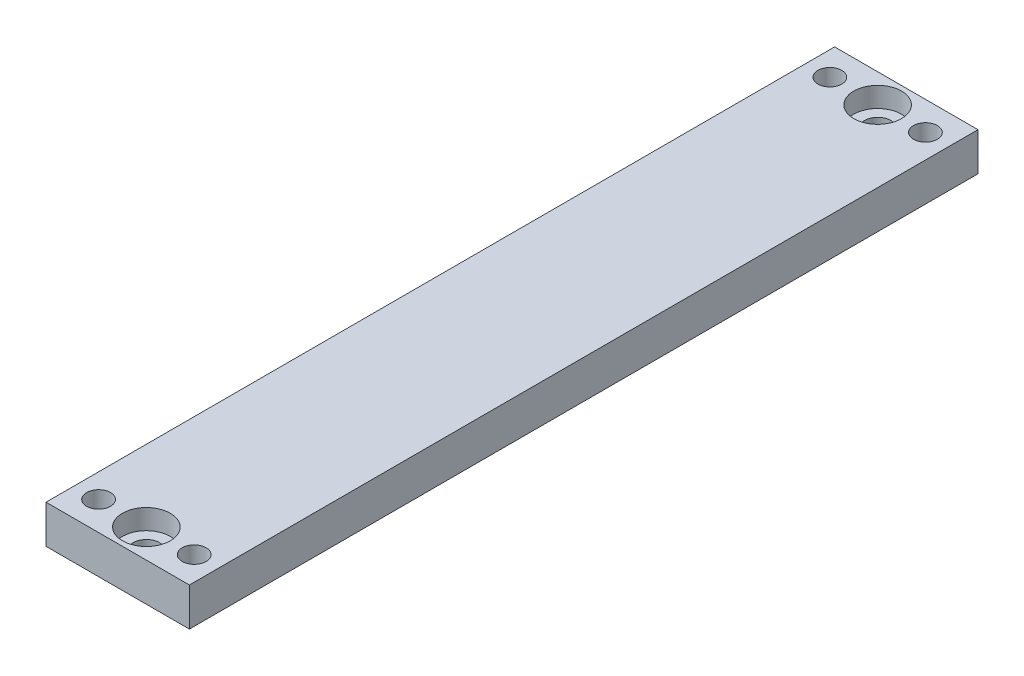
from build123d import *

# Parameters (mm, degrees)
SKETCH2_W           = 30
SKETCH2_H           = 165
BOSS_EXTRUDE1_DEPTH = 8
SKETCH3_R           = 2.75
CUT_EXTRUDE1_DEPTH  = 8
SKETCH4_R           = 5
CUT_EXTRUDE2_DEPTH  = 4.2
SKETCH5_R           = 2.5
CUT_EXTRUDE3_DEPTH  = 41.2


with BuildPart() as part:
    # Sketch2 → Boss-Extrude1 (new body)
    with BuildSketch(Plane(origin=(0, 0, 0), x_dir=(1, 0, 0), z_dir=(0, 1, 0))):
        Rectangle(SKETCH2_W, SKETCH2_H)
    extrude(amount=BOSS_EXTRUDE1_DEPTH)

    # Sketch3 → Cut-Extrude1 (cut)
    with BuildSketch(Plane(origin=(0, 8, 0), x_dir=(1, 0, 0), z_dir=(0, 1, 0))):
        with Locations((0, -76.5)):
            Circle(SKETCH3_R)
        with Locations((0, 76.5)):
            Circle(SKETCH3_R)
    extrude(amount=-CUT_EXTRUDE1_DEPTH, mode=Mode.SUBTRACT)

    # Sketch4 → Cut-Extrude2 (cut)
    with BuildSketch(Plane(origin=(0, 8, 0), x_dir=(1, 0, 0), z_dir=(0, 1, 0))):
        with Locations((0, 76.5)):
            Circle(SKETCH4_R)
        with Locations((0, -76.5)):
            Circle(SKETCH4_R)
    extrude(amount=-CUT_EXTRUDE2_DEPTH, mode=Mode.SUBTRACT)

    # Sketch5 → Cut-Extrude3 (cut)
    with BuildSketch(Plane(origin=(0, 8, 0), x_dir=(1, 0, 0), z_dir=(0, 1, 0))):
        with Locations((-10, 76.5)):
            Circle(SKETCH5_R)
        with Locations((10, 76.5)):
            Circle(SKETCH5_R)
        with Locations((-10, -76.5)):
            Circle(SKETCH5_R)
        with Locations((10, -76.5)):
            Circle(SKETCH5_R)
    extrude(amount=-CUT_EXTRUDE3_DEPTH, mode=Mode.SUBTRACT)


solid = part.part
